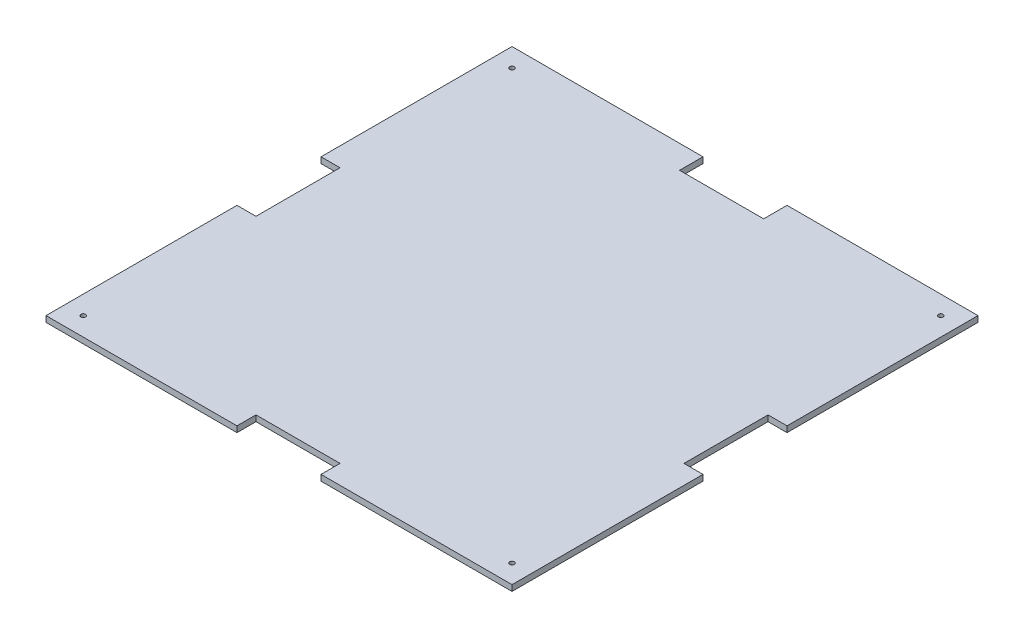
from build123d import *

# Parameters (mm, degrees)
SKETCH2_W          = 250
SKETCH2_H          = 250
BASE_DEPTH         = 3.175
SKETCH4_W          = 45.1
SKETCH4_H          = 25.1
SKETCH4_W_2        = 20.378913316
SKETCH4_H_2        = 45.1
SKETCH4_H_3        = 20.378913316
JIGSAW_DEPTH       = 10
STANDOFF_HOLES_D   = 2.5
STANDOFF_HOLES_2_D = 2.5


with BuildPart() as part:
    # Sketch2 → Base (new body)
    with BuildSketch(Plane(origin=(0, 0, 0), x_dir=(1, 0, 0), z_dir=(0, 1, 0))):
        Rectangle(SKETCH2_W, SKETCH2_H)
    extrude(amount=BASE_DEPTH)

    # Sketch4 → Jigsaw (cut)
    with BuildSketch(Plane(origin=(0, 3.175, 0), x_dir=(1, 0, 0), z_dir=(0, 1, 0))):
        with Locations((0, 125)):
            Rectangle(SKETCH4_W, SKETCH4_H)
        with Locations((-125, 0)):
            Rectangle(SKETCH4_W_2, SKETCH4_H_2)
        with Locations((125, 0)):
            Rectangle(SKETCH4_W_2, SKETCH4_H_2)
        with Locations((0, -125)):
            Rectangle(SKETCH4_W, SKETCH4_H_3)
    extrude(amount=-JIGSAW_DEPTH, mode=Mode.SUBTRACT)

    # Standoff Holes (through all)
    with Locations(Plane(origin=(0, 3.175, 0), x_dir=(1, 0, 0), z_dir=(0, 1, 0))):
        with Locations((-115, 115)):
            Hole(STANDOFF_HOLES_D / 2)

    # Standoff Holes 2 (through all)
    with Locations(Plane(origin=(0, 3.175, 0), x_dir=(1, 0, 0), z_dir=(0, 1, 0))):
        with Locations((115, 115), (115, -115), (-115, -115)):
            Hole(STANDOFF_HOLES_2_D / 2)


solid = part.part
